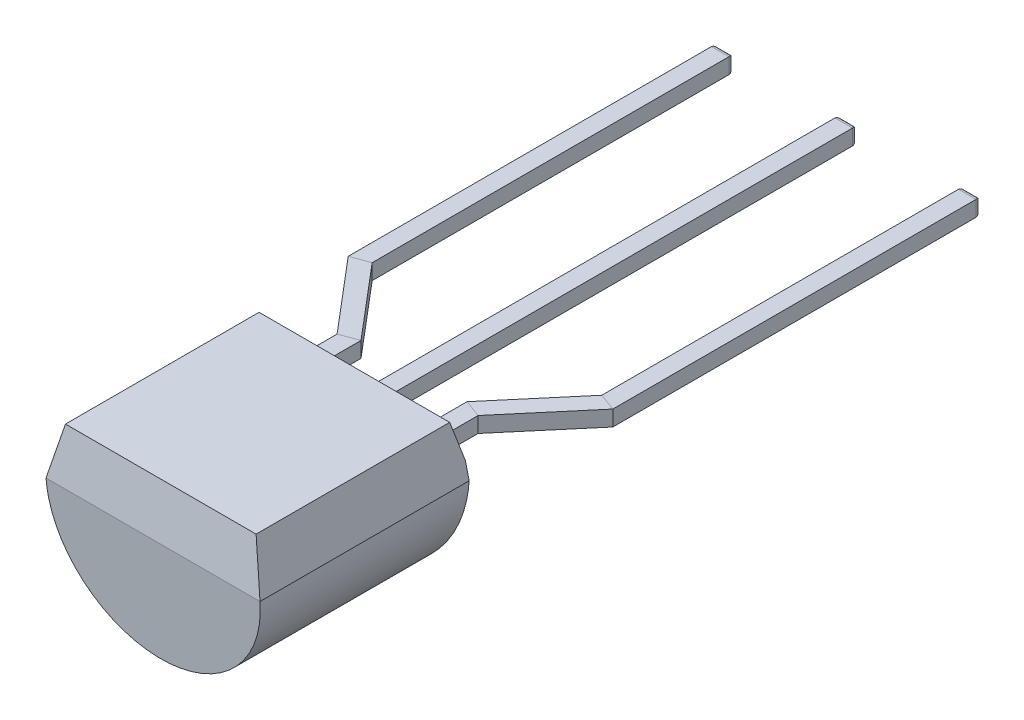
from build123d import *

# Parameters (mm, degrees)
BOSS_EXTRUDE1_DEPTH = 4.3
SKETCH2_W           = 0.36
SKETCH2_H           = 0.32
SKETCH2_4_W         = 0.36
SKETCH2_4_H         = 0.32
BOSS_EXTRUDE2_DEPTH = 10
FILLET1_R           = 0.1
SKETCH4_R           = 0.8
CUT_EXTRUDE1_DEPTH  = 0.25
CUT_EXTRUDE2_DEPTH  = 5
CUT_EXTRUDE3_DEPTH  = 5
CUT_EXTRUDE4_DEPTH  = 5
CUT_EXTRUDE6_DEPTH  = 5
SKETCH4_3_R         = 0.8
CUT_EXTRUDE8_DEPTH  = 0.3


with BuildPart() as part:
    # Sketch1 → Boss-Extrude1 (new body)
    with BuildSketch(Plane.XY):
        with BuildLine():
            Line((-1.959591794, 1), (-2.2, 0))
            ThreePointArc((-2.2, 0), (0, -2.2), (2.2, 0))
            Line((2.2, 0), (1.959591794, 1))
            Line((1.959591794, 1), (-1.959591794, 1))
        make_face()
    extrude(amount=BOSS_EXTRUDE1_DEPTH)

    # Sweep1: sweep along a curve in space
    with BuildLine() as sweep1_path:
        Line((1.27, 0.16, 0), (1.27, 0.16, -1))
        Line((1.27, 0.16, -1), (2.54, 0.16, -2.5))
        Line((2.54, 0.16, -10), (2.54, 0.16, -2.5))
    # Sketch2 → Sweep1 (sweep)
    with BuildSketch(Plane.XY):
        with Locations((1.27, 0.16)):
            Rectangle(SKETCH2_W, SKETCH2_H)
    sweep1 = sweep(path=sweep1_path.line, transition=Transition.RIGHT)

    # Mirror1: Sweep1 across plane
    add(sweep1.mirror(Plane(origin=(0, 0, 0), x_dir=(0, 0, 1), z_dir=(1, 0, 0))))

    # Sketch2_4 → Boss-Extrude2 (add)
    with BuildSketch(Plane.XY):
        with Locations((0, 0.16)):
            Rectangle(SKETCH2_4_W, SKETCH2_4_H)
    extrude(amount=-BOSS_EXTRUDE2_DEPTH)

    # Fillet1
    fillet1_edges = [part.edges().sort_by_distance(p)[0] for p in [
        (-2.54, 0.32, -10),
        (-2.72, 0.16, -10),
        (-2.54, 0, -10),
        (-2.36, 0.16, -10),
        (0, 0.32, -10),
        (-0.18, 0.16, -10),
        (0, 0, -10),
        (0.18, 0.16, -10),
        (2.36, 0.16, -10),
        (2.54, 0.32, -10),
        (2.72, 0.16, -10),
        (2.54, 0, -10),
    ]]
    fillet(fillet1_edges, radius=FILLET1_R)

    # Sketch4 → Cut-Extrude1 (cut)
    with BuildSketch(Plane(origin=(0, -2.2, 0), x_dir=(1, 0, 0), z_dir=(0, 1, 0))):
        with Locations((0, -2.15)):
            Circle(SKETCH4_R)
    extrude(amount=CUT_EXTRUDE1_DEPTH, mode=Mode.SUBTRACT)

    # Sketch5 → Cut-Extrude2 (cut)
    with BuildSketch(Plane(origin=(2.2, 0, 0), x_dir=(0, 0, -1), z_dir=(1, 0, 0))):
        Polygon((-4.3, 1), (-4.3, 0), (-4.14, 1), align=None)
    extrude(amount=-CUT_EXTRUDE2_DEPTH, mode=Mode.SUBTRACT)

    # Sketch6 → Cut-Extrude3 (cut)
    with BuildSketch(Plane(origin=(2.2, 0, 0), x_dir=(0, 0, -1), z_dir=(1, 0, 0))):
        Polygon((-4.3, 0), (-4.14, -2.2), (-4.3, -2.2), align=None)
    extrude(amount=-CUT_EXTRUDE3_DEPTH, mode=Mode.SUBTRACT)

    # Sketch7 → Cut-Extrude4 (cut)
    with BuildSketch(Plane(origin=(2.2, 0, 0), x_dir=(0, 0, -1), z_dir=(1, 0, 0))):
        Polygon((0, 0), (0, -2.2), (-0.16, -2.2), align=None)
    extrude(amount=-CUT_EXTRUDE4_DEPTH, mode=Mode.SUBTRACT)

    # Sketch8 → Cut-Extrude6 (cut)
    with BuildSketch(Plane(origin=(2.2, 0, 0), x_dir=(0, 0, -1), z_dir=(1, 0, 0))):
        Polygon((0, 0.32), (0, 1), (-0.16, 1), align=None)
    extrude(amount=-CUT_EXTRUDE6_DEPTH, mode=Mode.SUBTRACT)

    # Sketch4_3 → Cut-Extrude8 (cut)
    with BuildSketch(Plane(origin=(0, -2.2, 0), x_dir=(1, 0, 0), z_dir=(0, 1, 0))):
        with Locations((0, -2.15)):
            Circle(SKETCH4_3_R)
    extrude(amount=CUT_EXTRUDE8_DEPTH, mode=Mode.SUBTRACT)


solid = part.part
